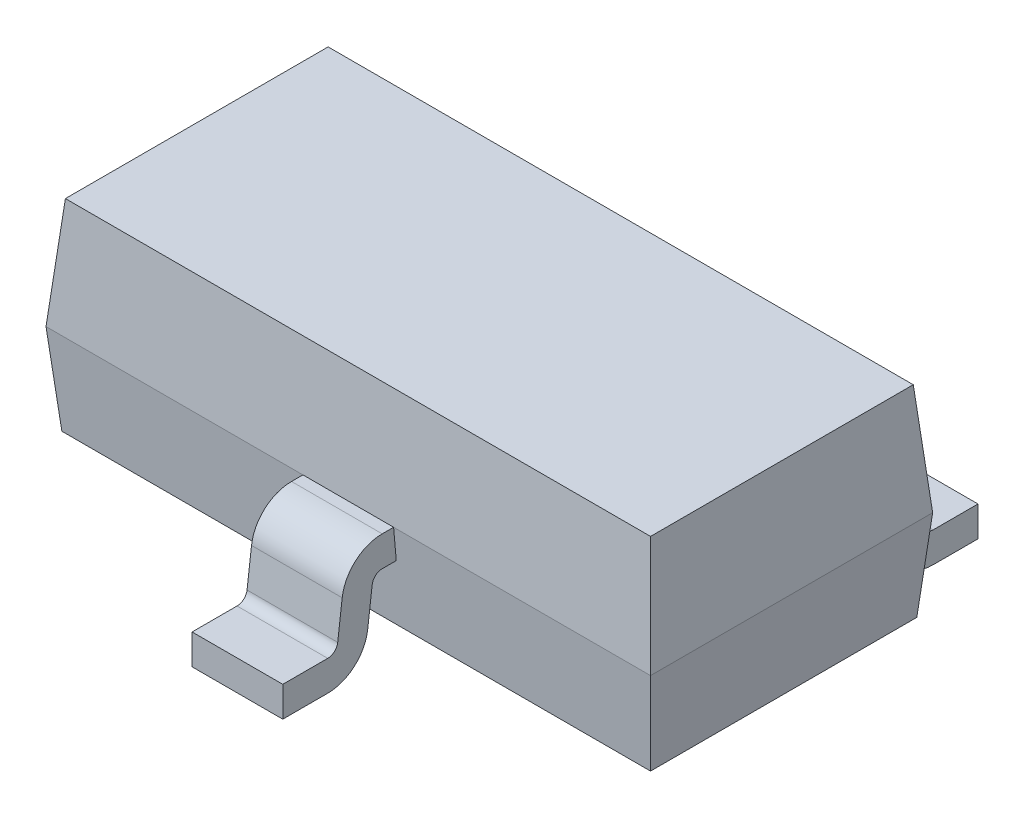
from build123d import *

# Parameters (mm, degrees)
SKETCH1_W                = 3
SKETCH1_H                = 1.4
EXTRUDE1_DEPTH           = 0.55
EXTRUDE1_TAPER           = 5
EXTRUDE1_OTHER_WAY_DEPTH = 0.45
EXTRUDE1_OTHER_WAY_TAPER = 5
EXTRUDE2_DEPTH           = 0.225
EXTRUDE2_DEPTH_BACK      = 0.225
EXTRUDE3_START           = 0.95
EXTRUDE3_DEPTH           = 0.225
FILLET1_R                = 0.05
FILLET2_R                = 0.2


with BuildPart() as part:
    # Sketch1 → Extrude1 (new body)
    with BuildSketch(Plane(origin=(0, 0, 0), x_dir=(1, 0, 0), z_dir=(0, 1, 0))):
        Rectangle(SKETCH1_W, SKETCH1_H)
    extrude(amount=EXTRUDE1_DEPTH, taper=EXTRUDE1_TAPER)

    # Sketch1 → Extrude1 other way (add)
    with BuildSketch(Plane(origin=(0, 0, 0), x_dir=(1, 0, 0), z_dir=(0, 1, 0))):
        Rectangle(SKETCH1_W, SKETCH1_H)
    extrude(amount=-EXTRUDE1_OTHER_WAY_DEPTH, taper=EXTRUDE1_OTHER_WAY_TAPER)

    # Sketch2 → Extrude2 (add, two sides)
    with BuildSketch(Plane(origin=(0, 0, 0), x_dir=(0, 0, -1), z_dir=(1, 0, 0))) as extrude2_sk:
        Polygon((-0.585273808, 0), (-0.933594965, 0), (-0.98270879, -0.4), (-1.25, -0.4), (-1.25, -0.55), (-0.85, -0.55), (-0.800886176, -0.15), (-0.585273808, -0.15), align=None)
    extrude(amount=EXTRUDE2_DEPTH)
    extrude(extrude2_sk.sketch, amount=-EXTRUDE2_DEPTH_BACK)

    # Sketch2_3 → Extrude3 (add, symmetric)
    with BuildSketch(Plane(origin=(0, 0, 0), x_dir=(0, 0, -1), z_dir=(1, 0, 0)).offset(EXTRUDE3_START)):
        Polygon((0.585273808, 0), (0.933594965, 0), (0.98270879, -0.4), (1.25, -0.4), (1.25, -0.55), (0.85, -0.55), (0.800886176, -0.15), (0.585273808, -0.15), align=None)
    extrude3 = extrude(amount=EXTRUDE3_DEPTH, both=True)

    # Mirror1: Extrude3 across plane
    add(extrude3.mirror(Plane(origin=(0, 0, 0), x_dir=(0, 0, 1), z_dir=(1, 0, 0))))

    # Fillet1
    fillet1_edges = [part.edges().sort_by_distance(p)[0] for p in [
        (0, -0.4, 0.98270879),
        (0, -0.15, 0.800886176),
        (0.95, -0.15, -0.800886176),
        (0.95, -0.4, -0.98270879),
        (-0.95, -0.4, -0.98270879),
        (-0.95, -0.15, -0.800886176),
    ]]
    fillet(fillet1_edges, radius=FILLET1_R)

    # Fillet2
    fillet2_edges = [part.edges().sort_by_distance(p)[0] for p in [
        (0, 0, 0.933594965),
        (0, -0.55, 0.85),
        (0.95, 0, -0.933594965),
        (0.95, -0.55, -0.85),
        (-0.95, 0, -0.933594965),
        (-0.95, -0.55, -0.85),
    ]]
    fillet(fillet2_edges, radius=FILLET2_R)


solid = part.part
